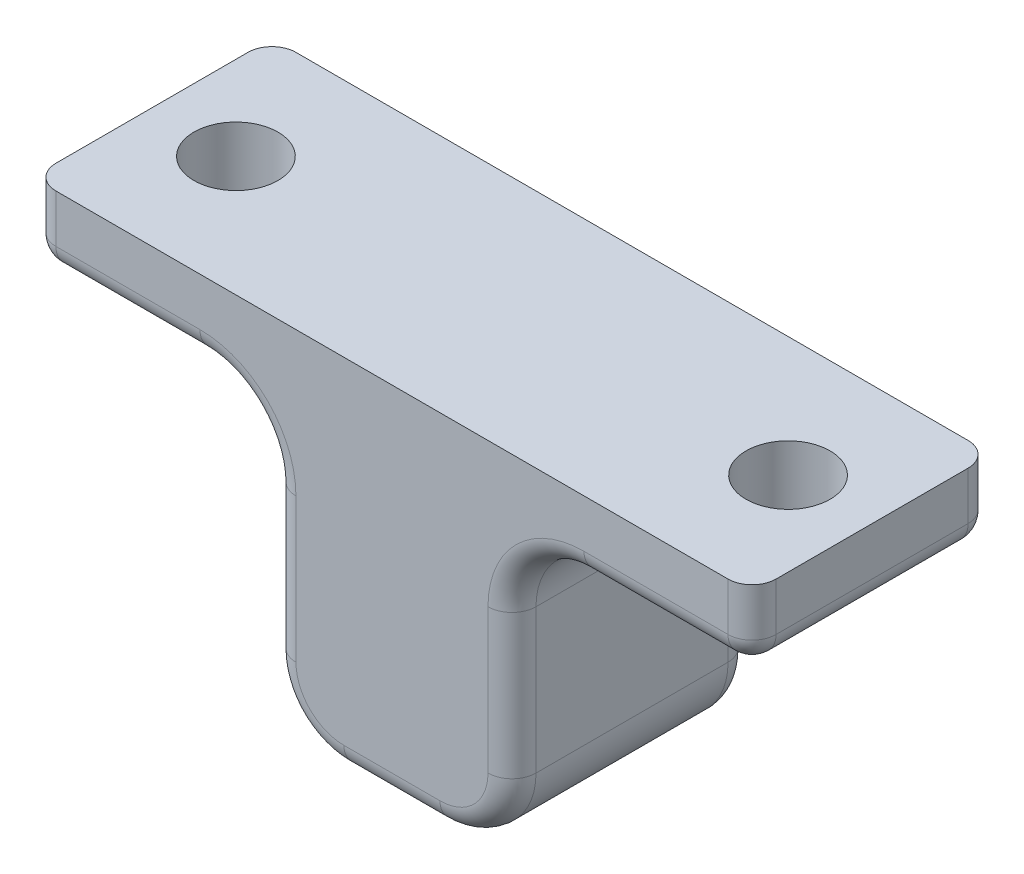
from build123d import *

# Parameters (mm, degrees)
SKETCH_1_W          = 10
SKETCH_1_H          = 3
EXTRUDE_1_DEPTH     = 10
SKETCH_2_R          = 3.2
CUT_EXTRUDE_1_DEPTH = 8
SKETCH_3_R          = 1.75
CUT_EXTRUDE_2_DEPTH = 4
FILLET_1_R          = 3
FILLET_2_R          = 1


with BuildPart() as part:
    # ｽｹｯﾁ1 → ﾎﾞｽ - 押し出し1 (new body)
    with BuildSketch(Plane.XY):
        Polygon((5, 10), (0, 10), (0, -5), (5, -5), (5, 7), align=None)
        with Locations((10, 8.5)):
            Rectangle(SKETCH_1_W, SKETCH_1_H)
        Polygon((0, -5), (0, 10), (-5, 10), (-5, 7), (-5, -5), align=None)
        with Locations((-10, 8.5)):
            Rectangle(SKETCH_1_W, SKETCH_1_H)
    extrude(amount=EXTRUDE_1_DEPTH)

    # ｽｹｯﾁ2 → ｶｯﾄ - 押し出し1 (cut)
    with BuildSketch(Plane(origin=(0, 0, 0), x_dir=(-1, 0, 0), z_dir=(0, 0, -1))):
        Circle(SKETCH_2_R)
    extrude(amount=-CUT_EXTRUDE_1_DEPTH, mode=Mode.SUBTRACT)

    # ｽｹｯﾁ3 → ｶｯﾄ - 押し出し2 (cut, through all)
    with BuildSketch(Plane.XZ.offset(-7)):
        with Locations((-11.5, 5)):
            Circle(SKETCH_3_R)
        with Locations((11.5, 5)):
            Circle(SKETCH_3_R)
    extrude(amount=-CUT_EXTRUDE_2_DEPTH, mode=Mode.SUBTRACT)

    # ﾌｨﾚｯﾄ1
    fillet_1_edges = [part.edges().sort_by_distance(p)[0] for p in [
        (5, -5, 5),
        (-5, -5, 5),
        (-5, 7, 5),
        (5, 7, 5),
    ]]
    fillet(fillet_1_edges, radius=FILLET_1_R)

    # ﾌｨﾚｯﾄ2
    fillet_2_edges = [part.edges().sort_by_distance(p)[0] for p in [
        (-15, 8.5, 0),
        (15, 8.5, 0),
        (15, 8.5, 10),
        (-15, 7, 5),
        (15, 7, 5),
        (-15, 8.5, 10),
        (-5, 1, 0),
        (-5, 1, 10),
        (-11.5, 7, 0),
        (-11.5, 7, 10),
        (11.5, 7, 0),
        (11.5, 7, 10),
        (5, 1, 0),
        (5, 1, 10),
        (0, -5, 0),
        (0, -5, 10),
        (4.121320344, -4.121320344, 0),
        (-4.121320344, -4.121320344, 0),
        (4.121320344, -4.121320344, 10),
        (-4.121320344, -4.121320344, 10),
        (-5.878679656, 6.121320344, 0),
        (-5.878679656, 6.121320344, 10),
        (5.878679656, 6.121320344, 0),
        (5.878679656, 6.121320344, 10),
    ]]
    fillet(fillet_2_edges, radius=FILLET_2_R)


solid = part.part
